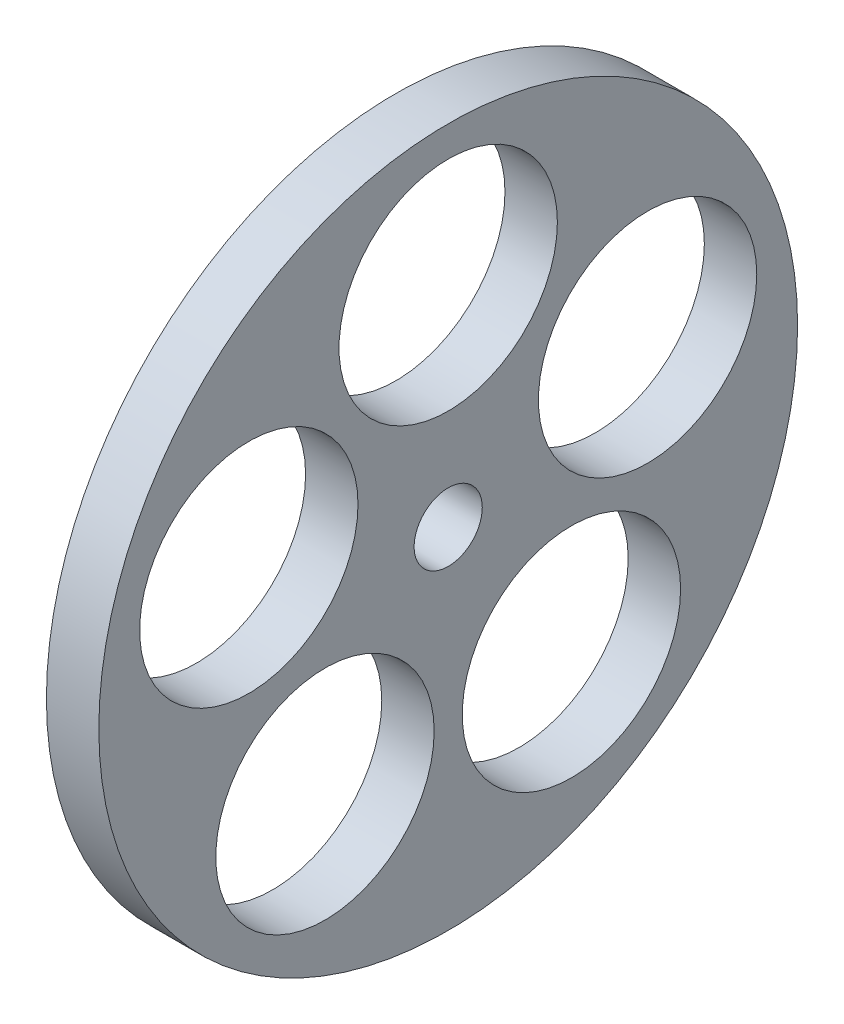
from build123d import *

# Parameters (mm, degrees)
SKETCH1_R           = 40
SKETCH1_R_2         = 3.9
SKETCH1_R_3         = 12.5
BOSS_EXTRUDE1_DEPTH = 6


with BuildPart() as part:
    # Sketch1 → Boss-Extrude1 (new body)
    with BuildSketch(Plane(origin=(0, 0, 0), x_dir=(0, 0, -1), z_dir=(1, 0, 0))):
        Circle(SKETCH1_R)
        Circle(SKETCH1_R_2, mode=Mode.SUBTRACT)
        with Locations((0, 24)):
            Circle(SKETCH1_R_3, mode=Mode.SUBTRACT)
        with Locations((22.825356391, 7.416407865)):
            Circle(SKETCH1_R_3, mode=Mode.SUBTRACT)
        with Locations((14.106846055, -19.416407865)):
            Circle(SKETCH1_R_3, mode=Mode.SUBTRACT)
        with Locations((-14.106846055, -19.416407865)):
            Circle(SKETCH1_R_3, mode=Mode.SUBTRACT)
        with Locations((-22.825356391, 7.416407865)):
            Circle(SKETCH1_R_3, mode=Mode.SUBTRACT)
    extrude(amount=BOSS_EXTRUDE1_DEPTH)


solid = part.part
